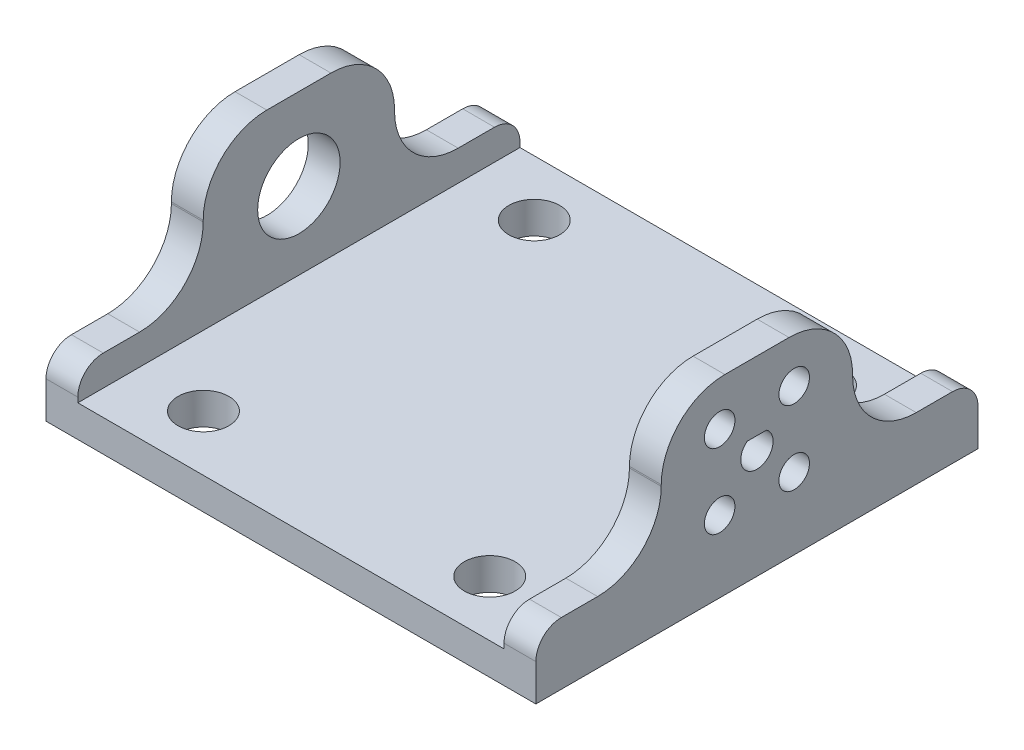
from build123d import *

# Parameters (mm, degrees)
SKETCH1_W             = 5
SKETCH1_H             = 69.5
BOSS_EXTRUDE1_DEPTH   = 30
BOSS_EXTRUDE1_2_DEPTH = 30
SKETCH1_4_W           = 67
SKETCH1_4_H           = 69.5
BOSS_EXTRUDE3_DEPTH   = 5
SKETCH2_R             = 6.477
CUT_EXTRUDE1_DEPTH    = 34
SKETCH3_R             = 4
CUT_EXTRUDE2_DEPTH    = 119
CUT_EXTRUDE3_DEPTH    = 14
SKETCH9_W             = 19.710117916
SKETCH9_H             = 20.225929664
CUT_EXTRUDE4_DEPTH    = 113
FILLET1_R             = 10
FILLET2_R             = 4
SKETCH11_R            = 2.4003
CUT_EXTRUDE5_DEPTH    = 5


with BuildPart() as part:
    # Sketch1 → Boss-Extrude1 (new body)
    with BuildSketch(Plane(origin=(0, 0, 0), x_dir=(1, 0, 0), z_dir=(0, 1, 0))):
        with Locations((-36, 0)):
            Rectangle(SKETCH1_W, SKETCH1_H)
    extrude(amount=BOSS_EXTRUDE1_DEPTH)



with BuildPart() as body_2:
    # Sketch1 → Boss-Extrude1 2 (new body)
    with BuildSketch(Plane(origin=(0, 0, 0), x_dir=(1, 0, 0), z_dir=(0, 1, 0))):
        with Locations((36, 0)):
            Rectangle(SKETCH1_W, SKETCH1_H)
    extrude(amount=BOSS_EXTRUDE1_2_DEPTH)


with BuildPart() as part_1:
    add(part.part)

    add(body_2.part)  # Boss-Extrude3 merges body 2
    # Sketch1_4 → Boss-Extrude3 (add)
    with BuildSketch(Plane(origin=(0, 0, 0), x_dir=(1, 0, 0), z_dir=(0, 1, 0))):
        Rectangle(SKETCH1_4_W, SKETCH1_4_H)
    extrude(amount=BOSS_EXTRUDE3_DEPTH)

    # Sketch2 → Cut-Extrude1 (cut)
    with BuildSketch(Plane.ZY.offset(38.5)):
        with Locations((0, 17.124630649)):
            Circle(SKETCH2_R)
    extrude(amount=-CUT_EXTRUDE1_DEPTH, mode=Mode.SUBTRACT)

    # Sketch3 → Cut-Extrude2 (cut)
    with BuildSketch(Plane(origin=(0, 5, 0), x_dir=(1, 0, 0), z_dir=(0, 1, 0))):
        with Locations((-22.5, 26)):
            Circle(SKETCH3_R)
        with Locations((-22.5, -26)):
            Circle(SKETCH3_R)
        with Locations((22.5, 26)):
            Circle(SKETCH3_R)
        with Locations((22.5, -26)):
            Circle(SKETCH3_R)
    extrude(amount=-CUT_EXTRUDE2_DEPTH, mode=Mode.SUBTRACT)

    # Sketch8 → Cut-Extrude3 (cut)
    with BuildSketch(Plane(origin=(38.5, 0, 0), x_dir=(0, 0, -1), z_dir=(1, 0, 0))):
        with BuildLine():
            Line((-1.524, 19.156630649), (1.524, 19.156630649))
            ThreePointArc((1.524, 19.156630649), (0, 14.584630649), (-1.524, 19.156630649))
        make_face()
    extrude(amount=-CUT_EXTRUDE3_DEPTH, mode=Mode.SUBTRACT)

    # Sketch9 → Cut-Extrude4 (cut)
    with BuildSketch(Plane.ZY.offset(38.5)):
        with Locations((-24.894941042, 19.887035168)):
            Rectangle(SKETCH9_W, SKETCH9_H)
        with Locations((24.894941042, 19.887035168)):
            Rectangle(SKETCH9_W, SKETCH9_H)
    extrude(amount=-CUT_EXTRUDE4_DEPTH, mode=Mode.SUBTRACT)

    # Fillet1
    fillet1_edges = [part_1.edges().sort_by_distance(p)[0] for p in [
        (36, 9.774070336, -15.039882084),
        (-36, 30, -15.039882084),
        (-36, 9.774070336, -15.039882084),
        (36, 9.774070336, 15.039882084),
        (-36, 9.774070336, 15.039882084),
        (-36, 30, 15.039882084),
        (36, 30, 15.039882084),
        (36, 30, -15.039882084),
    ]]
    fillet(fillet1_edges, radius=FILLET1_R)

    # Fillet2
    fillet2_edges = [part_1.edges().sort_by_distance(p)[0] for p in [
        (36, 9.774070336, -34.75),
        (-36, 9.774070336, -34.75),
        (36, 9.774070336, 34.75),
        (-36, 9.774070336, 34.75),
    ]]
    fillet(fillet2_edges, radius=FILLET2_R)

    # Sketch11 → Cut-Extrude5 (cut)
    with BuildSketch(Plane.ZY.offset(-33.5)):
        with Locations((-5.856308805, 22.980939454)):
            Circle(SKETCH11_R)
        with Locations((5.856308805, 22.980939454)):
            Circle(SKETCH11_R)
        with Locations((-5.856308805, 11.268321844)):
            Circle(SKETCH11_R)
        with Locations((5.856308805, 11.268321844)):
            Circle(SKETCH11_R)
    extrude(amount=-CUT_EXTRUDE5_DEPTH, mode=Mode.SUBTRACT)


solid = part_1.part
